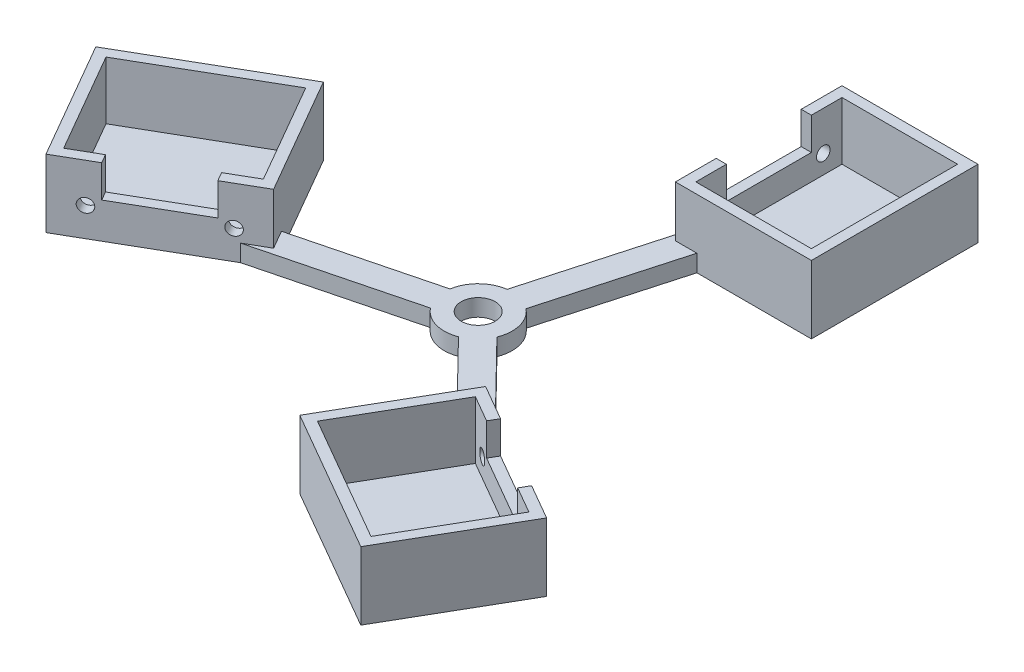
from build123d import *

# Parameters (mm, degrees)
BOSS_EXTRUDE3_DEPTH = 5
SKETCH3_W           = 40
SKETCH3_H           = 49
SKETCH3_W_2         = 34
SKETCH3_H_2         = 43
BOSS_EXTRUDE4_DEPTH = 10.5
SKETCH1_W           = 34
SKETCH1_H           = 43
BOSS_EXTRUDE5_DEPTH = 3
BOSS_EXTRUDE6_DEPTH = 9.5
SKETCH6_R           = 2
CUT_EXTRUDE1_DEPTH  = 3
CIRPATTERN1_COUNT   = 3
SKETCH8_R           = 5
CUT_EXTRUDE2_DEPTH  = 9.5


with BuildPart() as part:
    # Sketch4 → Boss-Extrude3 (new body)
    with BuildSketch(Plane(origin=(0, 0, 0), x_dir=(1, 0, 0), z_dir=(0, 1, 0))):
        with BuildLine():
            Line((6.323055165, 7.747191322), (17.313841595, 47))
            Line((17.313841595, 47), (11, 47))
            Line((11, 47), (11, 54.120862841))
            Line((11, 54.120862841), (-1.380656992, 9.904230726))
            ThreePointArc((-1.380656992, 9.904230726), (-2.696299255, -9.629640197), (6.323055165, 7.747191322))
        make_face()
    boss_extrude3 = extrude(amount=BOSS_EXTRUDE3_DEPTH)

    # Sketch3 → Boss-Extrude4 (add)
    with BuildSketch(Plane(origin=(0, 0, 0), x_dir=(1, 0, 0), z_dir=(0, 1, 0))):
        with Locations((31, 71.5)):
            Rectangle(SKETCH3_W, SKETCH3_H)
        with Locations((31, 71.5)):
            Rectangle(SKETCH3_W_2, SKETCH3_H_2, mode=Mode.SUBTRACT)
    boss_extrude4 = extrude(amount=BOSS_EXTRUDE4_DEPTH)

    # Sketch1 → Boss-Extrude5 (add)
    with BuildSketch(Plane(origin=(0, 0, 0), x_dir=(1, 0, 0), z_dir=(0, 1, 0))):
        with Locations((31, 71.5)):
            Rectangle(SKETCH1_W, SKETCH1_H)
    boss_extrude5 = extrude(amount=BOSS_EXTRUDE5_DEPTH)

    # Sketch7 → Boss-Extrude6 (add)
    with BuildSketch(Plane(origin=(0, 10.5, 0), x_dir=(1, 0, 0), z_dir=(0, 1, 0))):
        Polygon((14, 50), (14, 59), (11, 59), (11, 47), (51, 47), (51, 96), (11, 96), (11, 84), (14, 84), (14, 93), (48, 93), (48, 50), align=None)
    boss_extrude6 = extrude(amount=BOSS_EXTRUDE6_DEPTH)

    # Sketch6 → Cut-Extrude1 (cut)
    with BuildSketch(Plane(origin=(14, 0, 0), x_dir=(0, 0, -1), z_dir=(1, 0, 0))):
        with Locations((55.5, 8.5)):
            Circle(SKETCH6_R)
        with Locations((87.5, 8.5)):
            Circle(SKETCH6_R)
    cut_extrude1 = extrude(amount=-CUT_EXTRUDE1_DEPTH, mode=Mode.SUBTRACT)

    # CirPattern1: Boss-Extrude3, Boss-Extrude4, Boss-Extrude5, Boss-Extrude6, Cut-Extrude1 ×3 about axis
    cirpattern1_axis = Axis((0, 0, 0), (0, 1, 0))
    for i in range(1, CIRPATTERN1_COUNT):
        add(boss_extrude3.rotate(cirpattern1_axis, i * 360 / CIRPATTERN1_COUNT))
        add(boss_extrude4.rotate(cirpattern1_axis, i * 360 / CIRPATTERN1_COUNT))
        add(boss_extrude5.rotate(cirpattern1_axis, i * 360 / CIRPATTERN1_COUNT))
        add(boss_extrude6.rotate(cirpattern1_axis, i * 360 / CIRPATTERN1_COUNT))
        add(cut_extrude1.rotate(cirpattern1_axis, i * 360 / CIRPATTERN1_COUNT), mode=Mode.SUBTRACT)

    # Sketch8 → Cut-Extrude2 (cut)
    with BuildSketch(Plane(origin=(0, 5, 0), x_dir=(1, 0, 0), z_dir=(0, 1, 0))):
        Circle(SKETCH8_R)
    extrude(amount=-CUT_EXTRUDE2_DEPTH, mode=Mode.SUBTRACT)


solid = part.part
